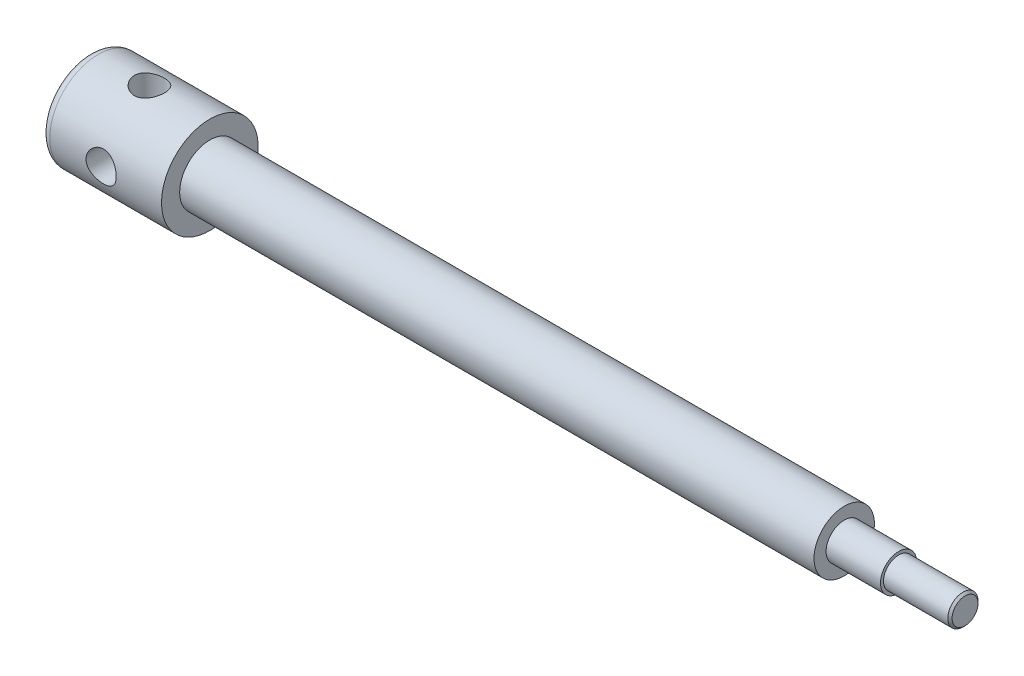
from build123d import *

# Parameters (mm, degrees)
SKETCH2_R          = 5
CUT_EXTRUDE1_DEPTH = 50
SKETCH3_R          = 5
CUT_EXTRUDE2_DEPTH = 50


with BuildPart() as part:
    # Sketch1 → Revolve1 (revolve)
    with BuildSketch(Plane.XY):
        with BuildLine():
            Line((238.015458409, 6), (238.015458409, 5))
            Line((238.015458409, 5), (259.308351628, 5))
            Line((259.308351628, 5), (260.015458409, 4.292893219))
            Line((260.015458409, 4.292893219), (260.015458409, 0))
            Line((260.015458409, 0), (-29.984541591, 0))
            Line((-29.984541591, 0), (-29.984541591, 13))
            ThreePointArc((-29.984541591, 13), (-29.105861935, 15.121320344), (-26.984541591, 16))
            Line((-26.984541591, 16), (10.015458409, 16))
            Line((10.015458409, 16), (10.015458409, 9.998359118))
            Line((10.015458409, 9.998359118), (220.015458409, 9.998359118))
            Line((220.015458409, 9.998359118), (220.015458409, 6))
            Line((220.015458409, 6), (238.015458409, 6))
        make_face()
    revolve(axis=Axis((-31.94536444, 0, 0), (1, 0, 0)))

    # Sketch2 → Cut-Extrude1 (cut, symmetric)
    with BuildSketch(Plane(origin=(0, 0, 0), x_dir=(1, 0, 0), z_dir=(0, 1, 0))):
        with Locations((-9.984541591, 0)):
            Circle(SKETCH2_R)
    extrude(amount=CUT_EXTRUDE1_DEPTH, both=True, mode=Mode.SUBTRACT)

    # Sketch3 → Cut-Extrude2 (cut, symmetric)
    with BuildSketch(Plane.XY):
        with Locations((-9.984541591, 0)):
            Circle(SKETCH3_R)
    extrude(amount=CUT_EXTRUDE2_DEPTH, both=True, mode=Mode.SUBTRACT)


solid = part.part
